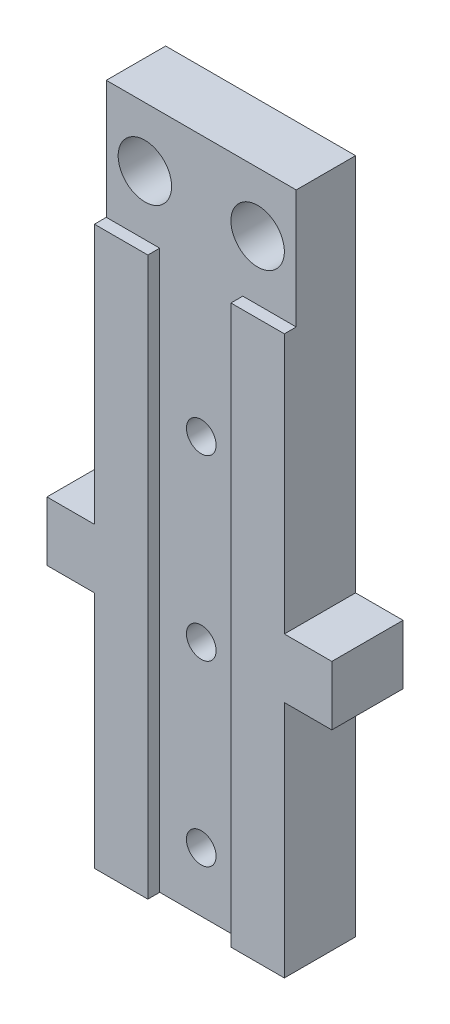
from build123d import *

# Parameters (mm, degrees)
SKETCH_1_W             = 16
SKETCH_1_H             = 57
EXTRUDE_1_DEPTH        = 6
SKETCH_2_W             = 31.720899854
SKETCH_2_H             = 10
CUT_EXTRUDE_1_DEPTH    = 1
SKETCH_3_W             = 4
SKETCH_3_H             = 5
EXTRUDE_2_DEPTH        = 6
HOLE_WIZARD_M3_1_D     = 2.5
HOLE_WIZARD_M3_1_DEPTH = 7.5
HOLE_WIZARD_M3_1_TIP   = 0.751075774
SKETCH_6_W             = 7
SKETCH_6_H             = 1
CUT_EXTRUDE_2_DEPTH    = 58
SKETCH_7_R             = 2.25
CUT_EXTRUDE_3_DEPTH    = 6


with BuildPart() as part:
    # 草图1 → 凸台-拉伸1 (new body)
    with BuildSketch(Plane.XY):
        with Locations((8, 28.5)):
            Rectangle(SKETCH_1_W, SKETCH_1_H)
    extrude(amount=EXTRUDE_1_DEPTH)

    # 草图2 → 切除-拉伸1 (cut)
    with BuildSketch(Plane.XY.offset(6)):
        with Locations((15.860449927, 52)):
            Rectangle(SKETCH_2_W, SKETCH_2_H)
    extrude(amount=-CUT_EXTRUDE_1_DEPTH, mode=Mode.SUBTRACT)

    # 草图3 → 凸台-拉伸2 (add)
    with BuildSketch(Plane(origin=(0, 0, 0), x_dir=(-1, 0, 0), z_dir=(0, 0, -1))):
        with Locations((-18, 22.6)):
            Rectangle(SKETCH_3_W, SKETCH_3_H)
        with Locations((2, 22.6)):
            Rectangle(SKETCH_3_W, SKETCH_3_H)
    extrude(amount=-EXTRUDE_2_DEPTH)

    # M3 螺纹孔1
    with Locations(Plane(origin=(0, 0, 0), x_dir=(-1, 0, 0), z_dir=(0, 0, -1))):
        with Locations((-8, 35), (-8, 20), (-8, 5)):
            Hole(HOLE_WIZARD_M3_1_D / 2, depth=HOLE_WIZARD_M3_1_DEPTH)
            with Locations((0, 0, -(HOLE_WIZARD_M3_1_DEPTH + HOLE_WIZARD_M3_1_TIP / 2))):  # 118° drill point
                Cone(0, HOLE_WIZARD_M3_1_D / 2, HOLE_WIZARD_M3_1_TIP, mode=Mode.SUBTRACT)

    # 草图6 → 切除-拉伸2 (cut, through all)
    with BuildSketch(Plane.XZ):
        with Locations((8, 5.5)):
            Rectangle(SKETCH_6_W, SKETCH_6_H)
    extrude(amount=-CUT_EXTRUDE_2_DEPTH, mode=Mode.SUBTRACT)

    # 草图7 → 切除-拉伸3 (cut, through all)
    with BuildSketch(Plane.XY.offset(5)):
        with Locations((3.25, 52)):
            Circle(SKETCH_7_R)
        with Locations((12.75, 52)):
            Circle(SKETCH_7_R)
    extrude(amount=-CUT_EXTRUDE_3_DEPTH, mode=Mode.SUBTRACT)


solid = part.part
